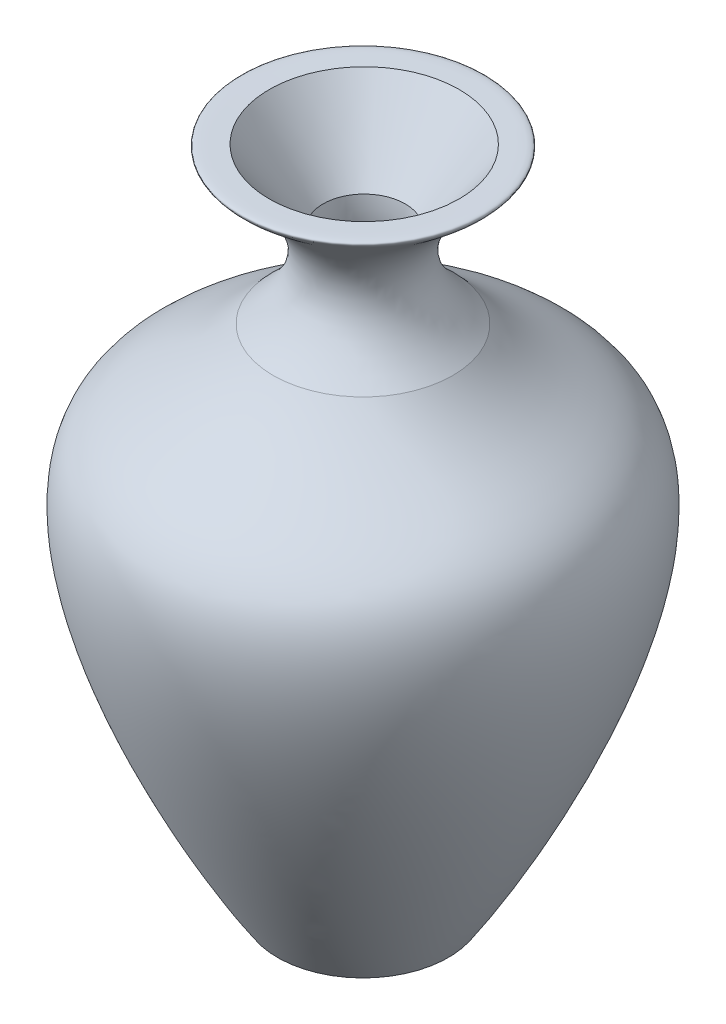
from build123d import *


with BuildPart() as part:
    # Sketch1 → Revolve1 (revolve)
    with BuildSketch(Plane.XY):
        with BuildLine():
            Line((-1.764853326, 3.715213709), (-5.819233909, 3.715213709))
            Line((-5.819233909, 3.715213709), (-5.819233909, 35.134493571))
            Line((-5.819233909, 35.134493571), (-2.435050467, 35.134493571))
            add(Edge.make_bspline(
                [(-2.435050467, 35.134493571), (-0.303241906, 35.033779017), (1.609505534, 35.870187318), (-5.382826884, 31.039920121), (-1.562034093, 27.720427487)],
                knots=[0, 0, 0, 0, 0.514505297, 1, 1, 1, 1], degree=3))
            add(Edge.make_bspline(
                [(-1.562034093, 27.720427487), (0.504481908, 25.302588125), (9.151601225, 23.453899576), (0.914400055, 7.715695587), (-1.764853326, 3.715213709)],
                knots=[0, 0, 0, 0, 0.292039145, 1, 1, 1, 1], degree=3))
        make_face()
    revolve(axis=Axis((-5.819233909, 35.134493571, 0), (0, -1, 0)))

    # Sketch2 → Cut-Revolve4 (revolve, cut)
    with BuildSketch(Plane.XY):
        with BuildLine():
            Line((-5.762234512, 35.283107664), (-1.14109655, 35.283107664))
            Line((-1.14109655, 35.283107664), (-3.813755554, 31.696645472))
            add(Edge.make_bspline(
                [(-3.813755554, 31.696645472), (-4.192225419, 28.969576306), (-2.322522019, 27.720427487)],
                knots=[0, 0, 0, 1, 1, 1], degree=2))
            add(Edge.make_bspline(
                [(-2.322522019, 27.720427487), (-0.735940168, 26.459290727), (6.440819143, 19.739927614), (-0.7536371, 8.778215117), (-2.931241799, 4.78978541)],
                knots=[0, 0, 0, 0, 0.258285294, 1, 1, 1, 1], degree=3))
            Line((-2.931241799, 4.78978541), (-5.762234512, 4.78978541))
            Line((-5.762234512, 4.78978541), (-5.762234512, 35.283107664))
        make_face()
    revolve(axis=Axis((-5.762234512, 4.78978541, 0), (0, 1, 0)), mode=Mode.SUBTRACT)


solid = part.part
